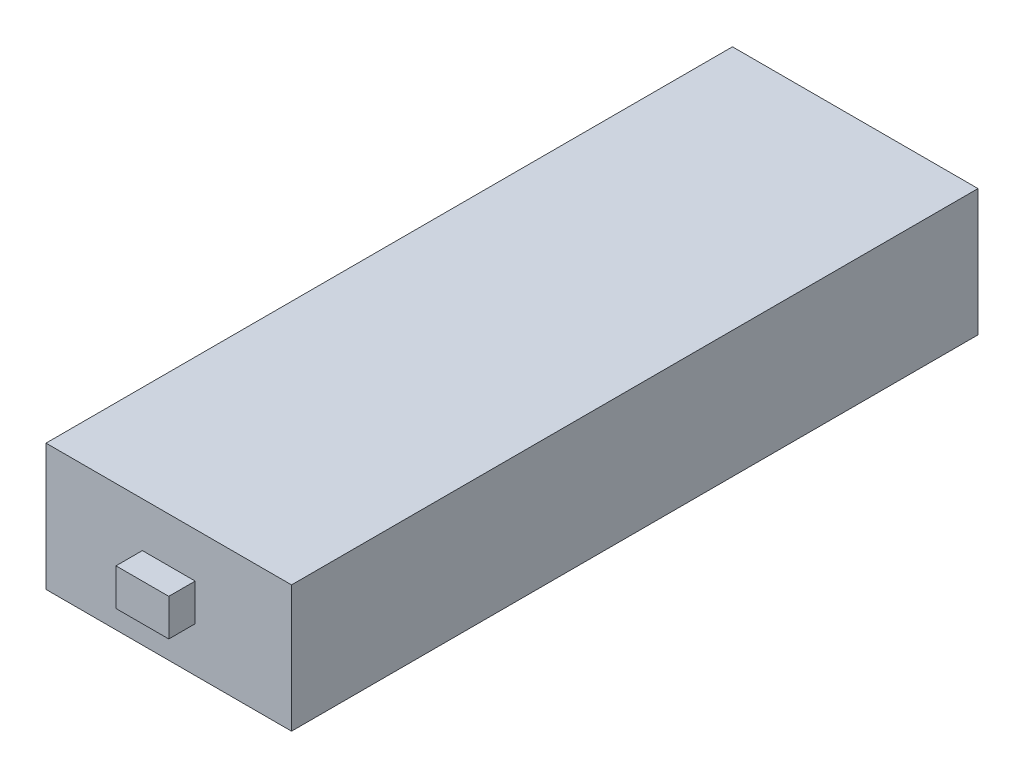
from build123d import *

# Parameters (mm, degrees)
SKETCH1_W    = 46.5
SKETCH1_H    = 130
BODY_DEPTH   = 24
SKETCH2_W    = 10
SKETCH2_H    = 7
CABLES_DEPTH = 5


with BuildPart() as part:
    # Sketch1 → body (new body)
    with BuildSketch(Plane(origin=(0, 0, 0), x_dir=(1, 0, 0), z_dir=(0, 1, 0))):
        Rectangle(SKETCH1_W, SKETCH1_H)
    extrude(amount=BODY_DEPTH)

    # Sketch2 → cables (add)
    with BuildSketch(Plane.XY.offset(65)):
        with Locations((0, 12)):
            Rectangle(SKETCH2_W, SKETCH2_H)
    extrude(amount=CABLES_DEPTH)


solid = part.part
